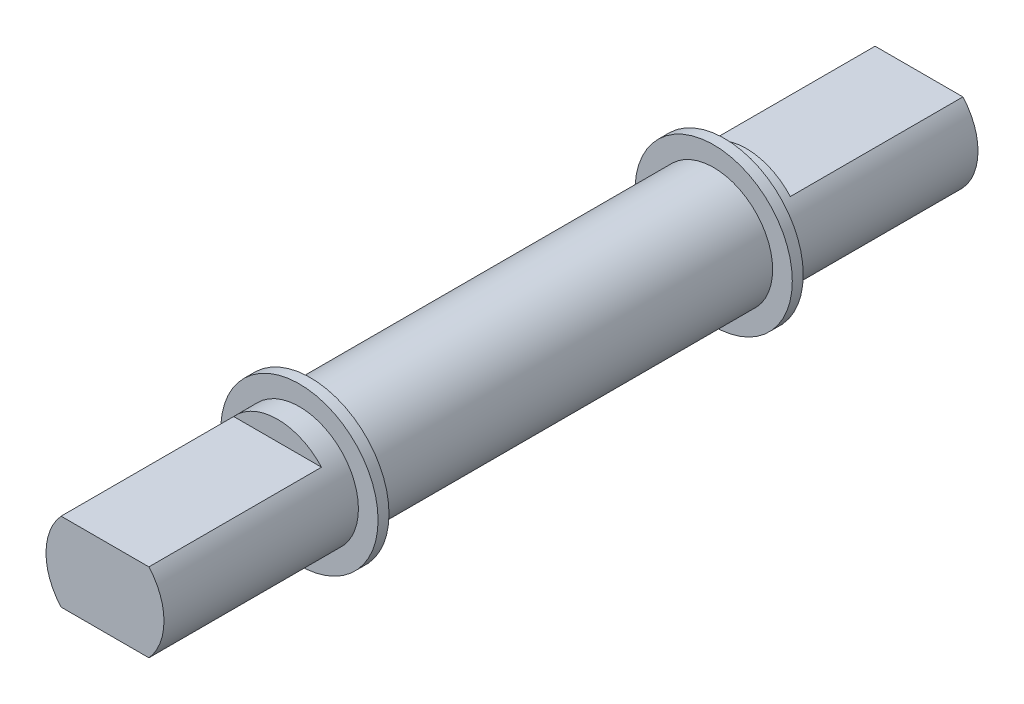
from build123d import *

# Parameters (mm, degrees)
SKETCH1_R           = 2.7
BOSS_EXTRUDE1_DEPTH = 9.23
SKETCH2_R           = 3.6
BOSS_EXTRUDE2_DEPTH = 0.5
SKETCH3_R           = 2.7
BOSS_EXTRUDE3_DEPTH = 1
BOSS_EXTRUDE4_DEPTH = 8.9


with BuildPart() as part:
    # Sketch1 → Boss-Extrude1 (new, symmetric)
    with BuildSketch(Plane.XY):
        Circle(SKETCH1_R)
    extrude(amount=BOSS_EXTRUDE1_DEPTH, both=True)

    # Sketch2 → Boss-Extrude2 (add)
    with BuildSketch(Plane.XY.offset(9.23)):
        Circle(SKETCH2_R)
    boss_extrude2 = extrude(amount=BOSS_EXTRUDE2_DEPTH)

    # Sketch3 → Boss-Extrude3 (add)
    with BuildSketch(Plane.XY.offset(9.73)):
        Circle(SKETCH3_R)
    boss_extrude3 = extrude(amount=BOSS_EXTRUDE3_DEPTH)

    # Sketch3_3 → Boss-Extrude4 (add)
    with BuildSketch(Plane.XY.offset(9.73)):
        with BuildLine():
            ThreePointArc((-2.01, 1.802747903), (-2.521606631, 0.965142477), (-2.7, 0))
            Line((-2.7, 0), (2.7, 0))
            ThreePointArc((2.7, 0), (2.521606631, 0.965142477), (2.01, 1.802747903))
            Line((2.01, 1.802747903), (-2.01, 1.802747903))
        make_face()
        with BuildLine():
            Line((2.7, 0), (-2.7, 0))
            ThreePointArc((-2.7, 0), (-2.521606631, -0.965142477), (-2.01, -1.802747903))
            Line((-2.01, -1.802747903), (2.01, -1.802747903))
            ThreePointArc((2.01, -1.802747903), (2.521606631, -0.965142477), (2.7, 0))
        make_face()
    boss_extrude4 = extrude(amount=BOSS_EXTRUDE4_DEPTH)

    # Mirror1: Boss-Extrude2, Boss-Extrude3, Boss-Extrude4 across plane
    add(boss_extrude2.mirror(Plane.XY))
    add(boss_extrude3.mirror(Plane.XY))
    add(boss_extrude4.mirror(Plane.XY))


solid = part.part
